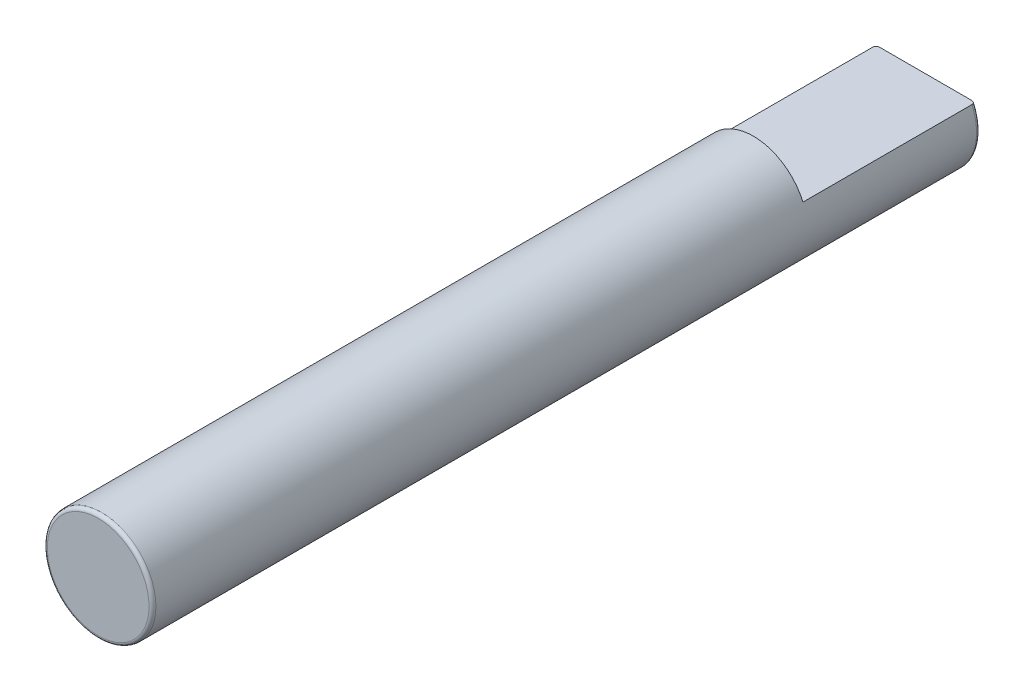
from build123d import *

# Parameters (mm, degrees)
SKETCH1_R           = 4
BOSS_EXTRUDE1_DEPTH = 60.96
FILLET2_R           = 0.254
SKETCH2_W           = 8
SKETCH2_H           = 12.7
CUT_EXTRUDE1_DEPTH  = 2.38125


with BuildPart() as part:
    # Sketch1 → Boss-Extrude1 (new body)
    with BuildSketch(Plane.XY):
        Circle(SKETCH1_R)
    extrude(amount=BOSS_EXTRUDE1_DEPTH)

    # Fillet2
    fillet2_edges = [part.edges().sort_by_distance(p)[0] for p in [
        (-4, 0, 0),
        (-4, 0, 60.96),
    ]]
    fillet(fillet2_edges, radius=FILLET2_R)

    # Sketch2 → Cut-Extrude1 (cut)
    with BuildSketch(Plane(origin=(0, 4, 0), x_dir=(1, 0, 0), z_dir=(0, 1, 0))):
        with Locations((0, -6.35)):
            Rectangle(SKETCH2_W, SKETCH2_H)
    extrude(amount=-CUT_EXTRUDE1_DEPTH, mode=Mode.SUBTRACT)


solid = part.part
